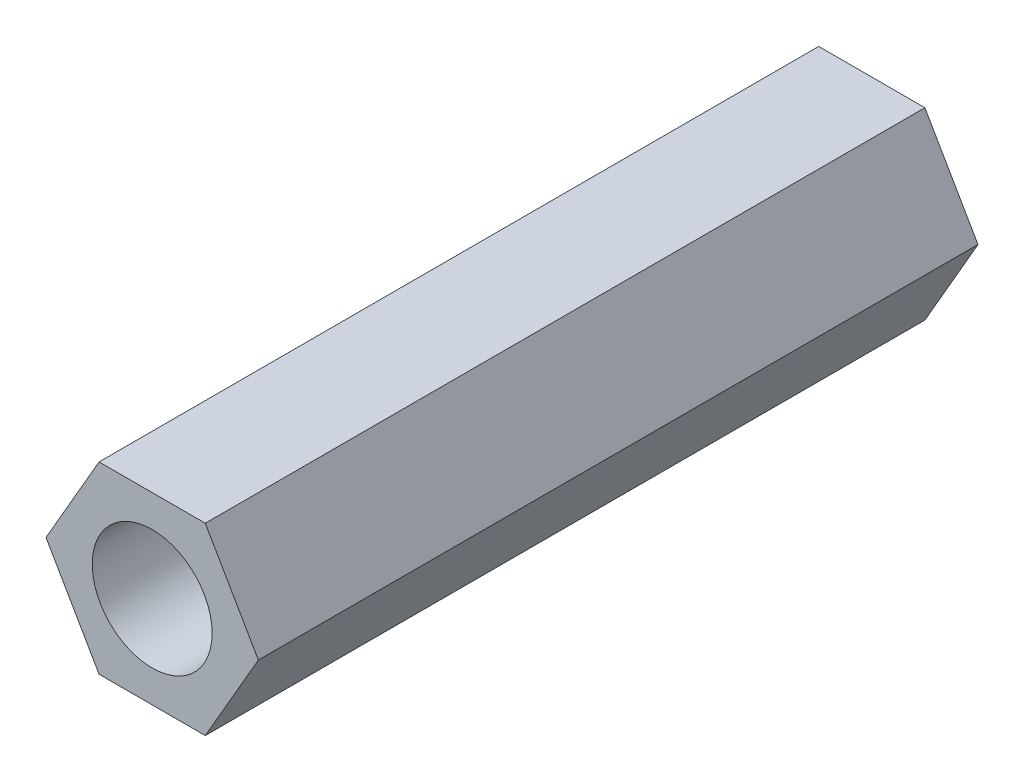
from build123d import *

# Parameters (mm, degrees)
SKETCH_1_R      = 1.5
EXTRUDE_1_DEPTH = 18


with BuildPart() as part:
    # 草图1 → 凸台-拉伸1 (new body)
    with BuildSketch(Plane.XY):
        Polygon((2.655811238, 0), (1.327905619, 2.3), (-1.327905619, 2.3), (-2.655811238, 0), (-1.327905619, -2.3), (1.327905619, -2.3), align=None)
        Circle(SKETCH_1_R, mode=Mode.SUBTRACT)
    extrude(amount=EXTRUDE_1_DEPTH)


solid = part.part
